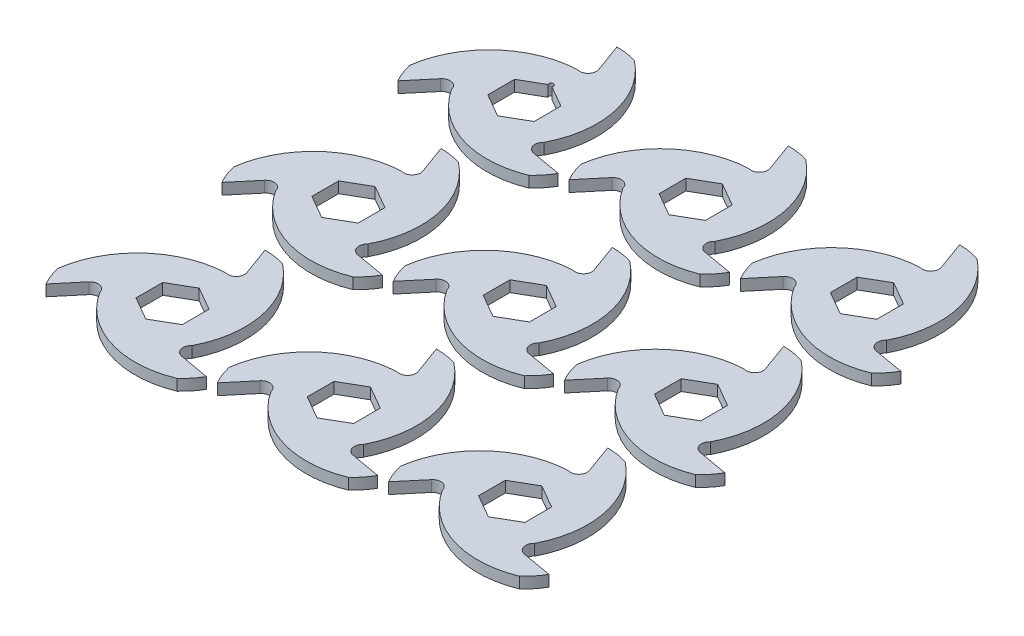
from build123d import *

# Parameters (mm, degrees)
BOSS_EXTRUDE2_DEPTH = 3.048
CUT_EXTRUDE1_DEPTH  = 7.096
LPATTERN1_COUNT     = 3
LPATTERN1_PITCH     = 96.52
LPATTERN1_2_COUNT   = 3
LPATTERN1_2_PITCH   = 93.98
SKETCH4_R           = 1.27
CUT_EXTRUDE2_DEPTH  = 7.096


with BuildPart() as part:
    # Sketch2 → Boss-Extrude2 (new body, symmetric)
    with BuildSketch(Plane(origin=(0, 0, 0), x_dir=(1, 0, 0), z_dir=(0, 1, 0))):
        with BuildLine():
            Line((0, 50.8), (5.699182497, 35.141624781))
            ThreePointArc((5.699182497, 35.141624781), (4.697625818, 30.400196659), (0, 29.21))
            ThreePointArc((0, 29.21), (-40.712457699, 16.982230342), (-43.994090512, -25.4))
            Line((-43.994090512, -25.4), (-33.283131039, -12.635175567))
            ThreePointArc((-33.283131039, -12.635175567), (-28.676155496, -11.131835033), (-25.296602045, -14.605))
            ThreePointArc((-25.296602045, -14.605), (5.64918596, -43.749137789), (43.994090512, -25.4))
            Line((43.994090512, -25.4), (27.583948542, -22.506449213))
            ThreePointArc((27.583948542, -22.506449213), (23.978529677, -19.268361626), (25.296602045, -14.605))
            ThreePointArc((25.296602045, -14.605), (35.063271738, 26.766907447), (0, 50.8))
        make_face()
        Polygon((0, 14.664696837), (12.7, 7.332348419), (12.7, -7.332348419), (0, -14.664696837), (-12.7, -7.332348419), (-12.7, 7.332348419), align=None, mode=Mode.SUBTRACT)
    extrude(amount=BOSS_EXTRUDE2_DEPTH, both=True)

    # Sketch3 → Cut-Extrude1 (cut, through all)
    with BuildSketch(Plane(origin=(0, 3.048, 0), x_dir=(1, 0, 0), z_dir=(0, 1, 0))):
        with BuildLine():
            ThreePointArc((0, 29.21), (-36.786884898, 21.158593478), (-48.137903328, -14.747595795))
            ThreePointArc((-48.137903328, -14.747595795), (-32.049598102, 15.970797155), (0, 29.21))
        make_face()
        with BuildLine():
            ThreePointArc((11.297159061, 49.062445064), (29.855915106, 19.77036756), (25.296602045, -14.605))
            ThreePointArc((25.296602045, -14.605), (36.717321909, 21.279080109), (11.297159061, 49.062445064))
        make_face()
        with BuildLine():
            ThreePointArc((-25.296602045, -14.605), (0.069562989, -42.437673587), (36.840744267, -34.314849269))
            ThreePointArc((36.840744267, -34.314849269), (2.193682996, -35.741164715), (-25.296602045, -14.605))
        make_face()
    extrude(amount=-CUT_EXTRUDE1_DEPTH, mode=Mode.SUBTRACT)


with BuildPart() as lpattern1_1:
    # LPattern1: pattern copy
    add(part.part.moved(Location(Vector(0, 0, 1) * (1 * LPATTERN1_PITCH))))


with BuildPart() as lpattern1_2:
    # LPattern1: pattern copy
    add(part.part.moved(Location(Vector(0, 0, 1) * (2 * LPATTERN1_PITCH))))


with BuildPart() as lpattern1_2_1:
    # LPattern1 2: pattern copy
    add(part.part.moved(Location(Vector(1, 0, 0) * (1 * LPATTERN1_2_PITCH))))


with BuildPart() as lpattern1_2_2:
    # LPattern1 2: pattern copy
    add(part.part.moved(Location(Vector(1, 0, 0) * (2 * LPATTERN1_2_PITCH))))


with BuildPart() as lpattern1_2_3:
    # LPattern1 2: pattern copy
    add(lpattern1_1.part.moved(Location(Vector(1, 0, 0) * (1 * LPATTERN1_2_PITCH))))


with BuildPart() as lpattern1_2_4:
    # LPattern1 2: pattern copy
    add(lpattern1_1.part.moved(Location(Vector(1, 0, 0) * (2 * LPATTERN1_2_PITCH))))


with BuildPart() as lpattern1_2_5:
    # LPattern1 2: pattern copy
    add(lpattern1_2.part.moved(Location(Vector(1, 0, 0) * (1 * LPATTERN1_2_PITCH))))


with BuildPart() as lpattern1_2_6:
    # LPattern1 2: pattern copy
    add(lpattern1_2.part.moved(Location(Vector(1, 0, 0) * (2 * LPATTERN1_2_PITCH))))


with BuildPart() as part_1:
    add(part.part)

    # Sketch4 → Cut-Extrude2 (cut, through all)
    with BuildSketch(Plane(origin=(0, 3.048, 0), x_dir=(1, 0, 0), z_dir=(0, 1, 0))):
        with Locations((0, 14.664696837)):
            Circle(SKETCH4_R)
    extrude(amount=-CUT_EXTRUDE2_DEPTH, mode=Mode.SUBTRACT)


solid = Compound([lpattern1_1.part, lpattern1_2.part, lpattern1_2_1.part, lpattern1_2_2.part, lpattern1_2_3.part, lpattern1_2_4.part, lpattern1_2_5.part, lpattern1_2_6.part, part_1.part])
